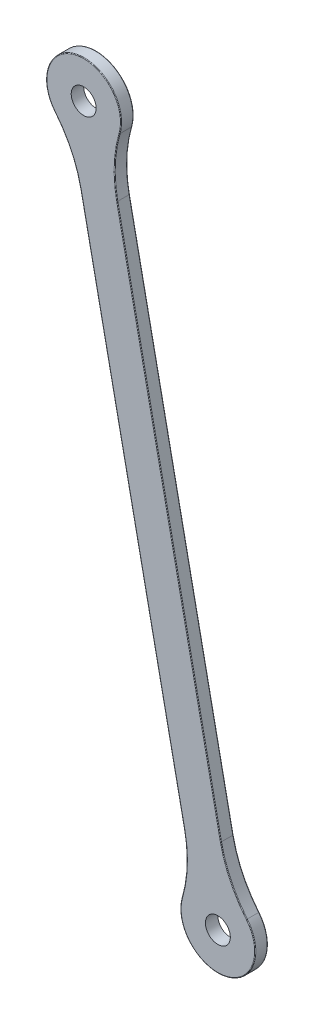
from build123d import *

# Parameters (mm, degrees)
BOSS_EXTRUDE1_DEPTH = 3
FILLET1_R           = 30
FILLET2_R           = 0.15
SKETCH2_R           = 4.65
SKETCH2_R_2         = 3
BOSS_EXTRUDE2_DEPTH = 3


with BuildPart() as part:
    # Sketch1 → Boss-Extrude1 (new body)
    with BuildSketch(Plane.XY):
        with BuildLine():
            ThreePointArc((7.448612374, 207.134028056), (-0.350164285, 222.673500313), (-1.365961708, 205.316534248))
            Line((-1.365961708, 205.316534248), (-2.939957518, 212.950179327))
            ThreePointArc((-2.939957518, 212.950179327), (0.558582619, 218.266213272), (5.874616565, 214.767673135))
            Line((5.874616565, 214.767673135), (7.448612374, 207.134028056))
        make_face()
        with BuildLine():
            Line((29.371043524, 56.246640082), (-2.939957518, 212.950179327))
            ThreePointArc((-2.939957518, 212.950179327), (2.376076428, 209.45163919), (5.874616565, 214.767673135))
            Line((5.874616565, 214.767673135), (38.185617606, 58.064133891))
            ThreePointArc((38.185617606, 58.064133891), (32.869583661, 61.562674028), (29.371043524, 56.246640082))
        make_face()
        with BuildLine():
            ThreePointArc((38.185617606, 58.064133891), (34.687077469, 52.748099945), (29.371043524, 56.246640082))
            Line((29.371043524, 56.246640082), (27.797047714, 63.880285161))
            ThreePointArc((27.797047714, 63.880285161), (35.595824373, 48.340812904), (36.611621797, 65.69777897))
            Line((36.611621797, 65.69777897), (38.185617606, 58.064133891))
        make_face()
    extrude(amount=-BOSS_EXTRUDE1_DEPTH)

    # Fillet1
    fillet1_edges = [part.edges().sort_by_distance(p)[0] for p in [
        (-1.365961708, 205.316534248, -1.5),
        (7.448612374, 207.134028056, -1.5),
        (36.611621797, 65.69777897, -1.5),
        (27.797047714, 63.880285161, -1.5),
    ]]
    fillet(fillet1_edges, radius=FILLET1_R)

    # Fillet2
    fillet2_edges = [part.edges().sort_by_distance(p)[0] for p in [
        (35.595824373, 48.340812904, 0),
        (35.595824373, 48.340812904, -3),
        (22.030117085, 136.415903513, 0),
        (22.030117085, 136.415903513, -3),
        (5.874616565, 214.767673135, -3),
        (13.215543003, 134.598409705, 0),
        (13.215543003, 134.598409705, -3),
        (-0.350164285, 222.673500313, 0),
        (-0.350164285, 222.673500313, -3),
        (36.828265789, 68.99602006, 0),
        (36.828265789, 68.99602006, -3),
        (26.293400844, 66.823816204, 0),
        (26.293400844, 66.823816204, -3),
        (-1.582605701, 202.018293157, 0),
        (34.687077469, 52.748099945, -3),
        (-1.582605701, 202.018293157, -3),
        (8.952259244, 204.190497013, 0),
        (8.952259244, 204.190497013, -3),
        (34.687077469, 52.748099945, 0),
        (5.874616565, 214.767673135, 0),
    ]]
    fillet(fillet2_edges, radius=FILLET2_R)

    # Sketch2 → Boss-Extrude2 (add)
    with BuildSketch(Plane.XY):
        with Locations((1.467329524, 213.858926231)):
            Circle(SKETCH2_R)
        with Locations((1.467329524, 213.858926231)):
            Circle(SKETCH2_R_2, mode=Mode.SUBTRACT)
        with Locations((33.778330565, 57.155386987)):
            Circle(SKETCH2_R)
        with Locations((33.778330565, 57.155386987)):
            Circle(SKETCH2_R_2, mode=Mode.SUBTRACT)
    extrude(amount=-BOSS_EXTRUDE2_DEPTH)


solid = part.part
